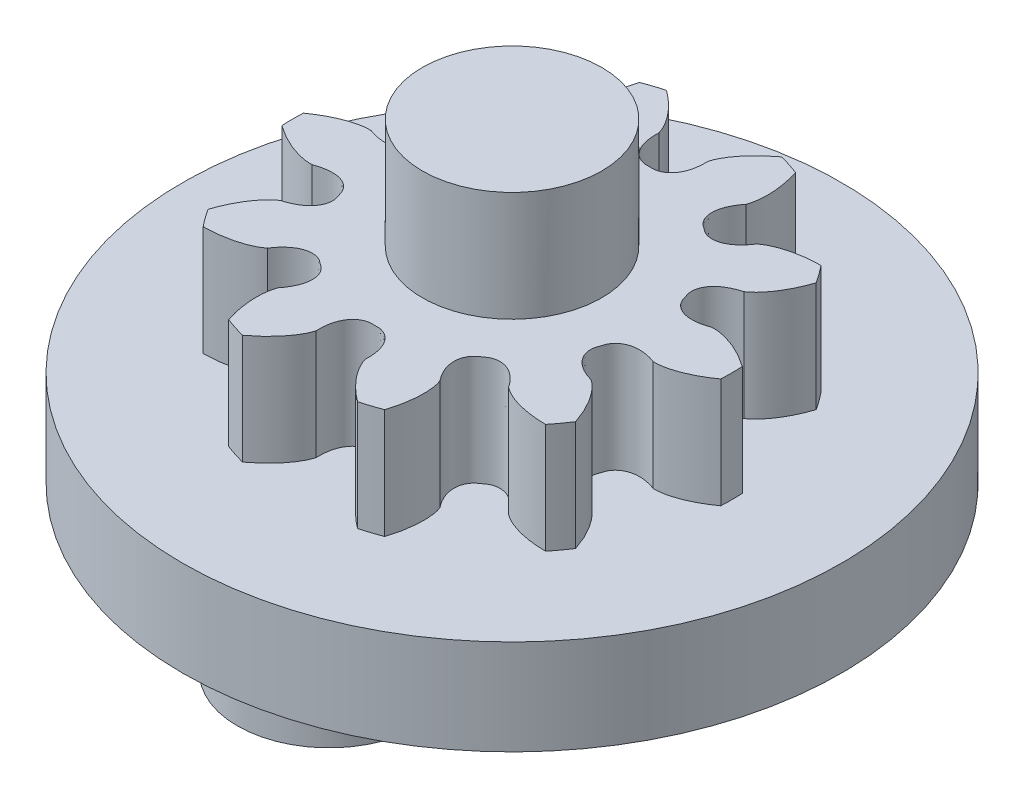
from build123d import *

# Parameters (mm, degrees)
SKETCH1_R           = 9
BOSS_EXTRUDE1_DEPTH = 2.6
SKETCH2_R           = 2.5
BOSS_EXTRUDE2_DEPTH = 7
BOSS_EXTRUDE3_DEPTH = 3
SKETCH4_R           = 2.45
BOSS_EXTRUDE4_DEPTH = 3


with BuildPart() as part:
    # Sketch1 → Boss-Extrude1 (new body)
    with BuildSketch(Plane(origin=(0, 0, 0), x_dir=(1, 0, 0), z_dir=(0, 1, 0))):
        Circle(SKETCH1_R)
    extrude(amount=BOSS_EXTRUDE1_DEPTH)

    # Sketch2 → Boss-Extrude2 (add)
    with BuildSketch(Plane.XZ):
        with Locations((-5, 0)):
            Circle(SKETCH2_R)
    extrude(amount=BOSS_EXTRUDE2_DEPTH)

    # Sketch3 → Boss-Extrude3 (add)
    with BuildSketch(Plane(origin=(0, 2.6, 0), x_dir=(1, 0, 0), z_dir=(0, 1, 0))):
        with BuildLine():
            ThreePointArc((-2.131306836, -5.60870138), (-1.854101966, -5.706339098), (-1.572448505, -5.790285459))
            add(Edge.make_bspline(
                [(-1.572448505, -5.790285459), (-1.524121757, -5.753776421), (-1.427468014, -5.680758158), (-1.29005992, -5.561733251), (-1.159069112, -5.435753819), (-1.036126032, -5.301847985), (-0.92251263, -5.159932716), (-0.837301737, -5.034588255), (-0.776335293, -4.929887877), (-0.735125884, -4.848929659), (-0.698268351, -4.765746753), (-0.680638314, -4.707778502), (-0.671824783, -4.678799267)],
                knots=[0, 0, 0, 0, 0.010251706, 0.020503464, 0.030755047, 0.041006321, 0.051257106, 0.061507029, 0.066633012, 0.071758798, 0.07688417, 0.082007812, 0.082007812, 0.082007812, 0.082007812], degree=3, weights=[1, 1, 1, 1, 1, 1, 1, 1, 1, 1, 1, 1, 1]))
            add(Edge.make_bspline(
                [(-0.671824783, -4.678799267), (-0.672788438, -4.651496326), (-0.674715723, -4.596891171), (-0.67266211, -4.514929148), (-0.666126837, -4.433177326), (-0.653115793, -4.352246289), (-0.637164096, -4.271797271), (-0.612712294, -4.193474838), (-0.58299038, -4.117042318), (-0.545673731, -4.043909177), (-0.500291897, -3.975487721), (-0.447276365, -3.912783717), (-0.386261642, -3.857704877), (-0.317525574, -3.812703152), (-0.243061735, -3.777838125), (-0.176887172, -3.760110426), (-0.122948454, -3.751154668), (-0.068263798, -3.749181842), (0, -3.750545471), (0.068263798, -3.749181842), (0.122948454, -3.751154668), (0.176887172, -3.760110426), (0.243061735, -3.777838125), (0.317525574, -3.812703152), (0.386261642, -3.857704877), (0.447276365, -3.912783717), (0.500291897, -3.975487721), (0.545673731, -4.043909177), (0.58299038, -4.117042318), (0.612712294, -4.193474838), (0.637164096, -4.271797271), (0.653115793, -4.352246289), (0.666126837, -4.433177326), (0.67266211, -4.514929148), (0.674715723, -4.596891171), (0.672788438, -4.651496326), (0.671824783, -4.678799267)],
                knots=[0, 0, 0, 0, 0.003643402, 0.007286706, 0.010929975, 0.01457286, 0.01821558, 0.021858686, 0.025500936, 0.029144127, 0.032787024, 0.036428762, 0.040069815, 0.043709849, 0.04734977, 0.050988094, 0.052810356, 0.054631699, 0.058275045, 0.061918391, 0.063739733, 0.065561995, 0.069200319, 0.07284024, 0.076480275, 0.080121327, 0.083763065, 0.087405962, 0.091049153, 0.094691403, 0.098334509, 0.101977229, 0.105620114, 0.109263383, 0.112906688, 0.116550089, 0.116550089, 0.116550089, 0.116550089], degree=3, weights=[1, 1, 1, 1, 1, 1, 1, 1, 1, 1, 1, 1, 1, 1, 1, 1, 1, 1, 1, 1, 1, 1, 1, 1, 1, 1, 1, 1, 1, 1, 1, 1, 1, 1, 1, 1, 1]))
            add(Edge.make_bspline(
                [(0.671824783, -4.678799267), (0.680638314, -4.707778502), (0.698268351, -4.765746753), (0.735125884, -4.848929659), (0.776335293, -4.929887877), (0.837301737, -5.034588255), (0.92251263, -5.159932716), (1.036126032, -5.301847985), (1.159069112, -5.435753819), (1.29005992, -5.561733251), (1.427468014, -5.680758158), (1.524121757, -5.753776421), (1.572448505, -5.790285459)],
                knots=[0, 0, 0, 0, 0.002373455, 0.004747711, 0.007122158, 0.009496697, 0.014244829, 0.01899336, 0.023742117, 0.028491018, 0.03324, 0.037988957, 0.037988957, 0.037988957, 0.037988957], degree=3, weights=[1, 1, 1, 1, 1, 1, 1, 1, 1, 1, 1, 1, 1]))
            ThreePointArc((1.572448505, -5.790285459), (1.854101966, -5.706339098), (2.131306836, -5.60870138))
            add(Edge.make_bspline(
                [(2.131306836, -5.60870138), (2.148944522, -5.550759198), (2.184219984, -5.434874537), (2.225424383, -5.257814913), (2.25734932, -5.078900947), (2.278104487, -4.898304722), (2.286603958, -4.716712576), (2.281865393, -4.565221071), (2.269646944, -4.444681509), (2.25540001, -4.354962652), (2.236324695, -4.266001953), (2.216514811, -4.208741977), (2.206611541, -4.180116819)],
                knots=[0, 0, 0, 0, 0.018166013, 0.036332118, 0.054497913, 0.072663161, 0.090827541, 0.108990394, 0.11807363, 0.127156519, 0.136238672, 0.145317761, 0.145317761, 0.145317761, 0.145317761], degree=3, weights=[1, 1, 1, 1, 1, 1, 1, 1, 1, 1, 1, 1, 1]))
            add(Edge.make_bspline(
                [(2.206611541, -4.180116819), (2.189783662, -4.158594699), (2.156128351, -4.11555103), (2.10961369, -4.048035277), (2.066848322, -3.978055327), (2.029804408, -3.904933043), (1.995422855, -3.830472247), (1.969168007, -3.75273566), (1.948287632, -3.673430349), (1.935490854, -3.592330219), (1.931988406, -3.510301326), (1.938022384, -3.428410974), (1.955009802, -3.347987702), (1.984167098, -3.271178494), (2.023916461, -3.199203349), (2.067032727, -3.145964907), (2.105406004, -3.107015163), (2.148487222, -3.073276279), (2.204515316, -3.034255025), (2.258940368, -2.993027372), (2.304340782, -2.962480587), (2.353242184, -2.938021565), (2.41719861, -2.913467142), (2.49793427, -2.897904795), (2.579994267, -2.893909908), (2.661730745, -2.902606072), (2.7414777, -2.922172928), (2.818409497, -2.950852276), (2.891585883, -2.988084054), (2.960557324, -3.032449159), (3.026376018, -3.08144093), (3.086567959, -3.137149381), (3.144664185, -3.194976265), (3.198003847, -3.257273541), (3.247841323, -3.322375128), (3.278378222, -3.367684455), (3.293646874, -3.39033942)],
                knots=[0, 0, 0, 0, 0.008194405, 0.016388591, 0.024582696, 0.03277594, 0.040968812, 0.04916255, 0.057354364, 0.065548295, 0.073741565, 0.081932227, 0.090121349, 0.09830818, 0.106494756, 0.114677741, 0.118776206, 0.122872602, 0.131066881, 0.139261161, 0.143357557, 0.147456021, 0.155639006, 0.163825582, 0.172012413, 0.180201535, 0.188392198, 0.196585467, 0.204779398, 0.212971212, 0.221164951, 0.229357823, 0.237551066, 0.245745171, 0.253939358, 0.262133762, 0.262133762, 0.262133762, 0.262133762], degree=3, weights=[1, 1, 1, 1, 1, 1, 1, 1, 1, 1, 1, 1, 1, 1, 1, 1, 1, 1, 1, 1, 1, 1, 1, 1, 1, 1, 1, 1, 1, 1, 1, 1, 1, 1, 1, 1, 1]))
            add(Edge.make_bspline(
                [(3.293646874, -3.39033942), (3.317810738, -3.408603651), (3.36614662, -3.445138275), (3.444858677, -3.490770346), (3.525783835, -3.532044637), (3.636648062, -3.580913845), (3.779260749, -3.632233938), (3.954591624, -3.68026552), (4.132762539, -3.716333486), (4.312785181, -3.741258522), (4.493911749, -3.756785244), (4.615025328, -3.759046615), (4.675581963, -3.760177297)],
                knots=[0, 0, 0, 0, 0.009079089, 0.018161243, 0.027244131, 0.036327367, 0.05449022, 0.072654601, 0.090819848, 0.108985643, 0.127151749, 0.145317761, 0.145317761, 0.145317761, 0.145317761], degree=3, weights=[1, 1, 1, 1, 1, 1, 1, 1, 1, 1, 1, 1, 1]))
            ThreePointArc((4.675581963, -3.760177297), (4.854101966, -3.526711514), (5.020975406, -3.284784006))
            add(Edge.make_bspline(
                [(5.020975406, -3.284784006), (5.001187034, -3.227540624), (4.961610188, -3.113053568), (4.890872211, -2.945589986), (4.811537037, -2.782080539), (4.722176522, -2.623775544), (4.622315553, -2.471868547), (4.529437501, -2.352094604), (4.448701191, -2.261757874), (4.384439758, -2.197547932), (4.316717717, -2.136789403), (4.267034616, -2.102109067), (4.242197256, -2.084771824)],
                knots=[0, 0, 0, 0, 0.018166013, 0.036332118, 0.054497913, 0.072663161, 0.090827541, 0.108990394, 0.11807363, 0.127156519, 0.136238672, 0.145317761, 0.145317761, 0.145317761, 0.145317761], degree=3, weights=[1, 1, 1, 1, 1, 1, 1, 1, 1, 1, 1, 1, 1]))
            add(Edge.make_bspline(
                [(4.242197256, -2.084771824), (4.215932831, -2.077251242), (4.163404679, -2.062210278), (4.086088763, -2.034929518), (4.010357671, -2.003451402), (3.937408315, -1.966068098), (3.865826097, -1.926037018), (3.798893059, -1.87857901), (3.735385989, -1.826692843), (3.677363718, -1.768603217), (3.626314804, -1.704299135), (3.583062453, -1.634501765), (3.54953395, -1.559453018), (3.527975379, -1.480174835), (3.51782736, -1.39858163), (3.521416381, -1.33016772), (3.529566929, -1.27610147), (3.544589148, -1.223483634), (3.56698071, -1.158982289), (3.586778496, -1.093638174), (3.605553252, -1.042239612), (3.630738665, -0.993708325), (3.668047774, -0.936250736), (3.724216976, -0.876205302), (3.788256773, -0.824739715), (3.859494449, -0.783731563), (3.935512201, -0.752687398), (4.01460863, -0.730670102), (4.095693859, -0.717779242), (4.177570082, -0.71313097), (4.259615165, -0.714078888), (4.341056073, -0.723768037), (4.422046697, -0.736402864), (4.50181681, -0.755450152), (4.580401928, -0.778824708), (4.631738953, -0.797531586), (4.657407806, -0.806885149)],
                knots=[0, 0, 0, 0, 0.008194405, 0.016388591, 0.024582696, 0.03277594, 0.040968812, 0.04916255, 0.057354364, 0.065548295, 0.073741565, 0.081932227, 0.090121349, 0.09830818, 0.106494756, 0.114677741, 0.118776206, 0.122872602, 0.131066881, 0.139261161, 0.143357557, 0.147456021, 0.155639006, 0.163825582, 0.172012413, 0.180201535, 0.188392198, 0.196585467, 0.204779398, 0.212971212, 0.221164951, 0.229357823, 0.237551066, 0.245745171, 0.253939358, 0.262133762, 0.262133762, 0.262133762, 0.262133762], degree=3, weights=[1, 1, 1, 1, 1, 1, 1, 1, 1, 1, 1, 1, 1, 1, 1, 1, 1, 1, 1, 1, 1, 1, 1, 1, 1, 1, 1, 1, 1, 1, 1, 1, 1, 1, 1, 1, 1]))
            add(Edge.make_bspline(
                [(4.657407806, -0.806885149), (4.687692228, -0.807458059), (4.748271292, -0.808604072), (4.838772541, -0.799255407), (4.928502789, -0.785080395), (5.046918433, -0.759452057), (5.192459714, -0.717145251), (5.362537627, -0.652946714), (5.527881144, -0.577400075), (5.688173089, -0.491750199), (5.843833939, -0.397848055), (5.943146083, -0.328488767), (5.992802028, -0.293809212)],
                knots=[0, 0, 0, 0, 0.009079089, 0.018161243, 0.027244131, 0.036327367, 0.05449022, 0.072654601, 0.090819848, 0.108985643, 0.127151749, 0.145317761, 0.145317761, 0.145317761, 0.145317761], degree=3, weights=[1, 1, 1, 1, 1, 1, 1, 1, 1, 1, 1, 1, 1]))
            ThreePointArc((5.992802028, -0.293809212), (6, 0), (5.992802028, 0.293809212))
            add(Edge.make_bspline(
                [(5.992802028, 0.293809212), (5.943146083, 0.328488767), (5.843833939, 0.397848055), (5.688173089, 0.491750199), (5.527881144, 0.577400075), (5.362537627, 0.652946714), (5.192459714, 0.717145251), (5.046918433, 0.759452057), (4.928502789, 0.785080395), (4.838772541, 0.799255407), (4.748271292, 0.808604072), (4.687692228, 0.807458059), (4.657407806, 0.806885149)],
                knots=[0, 0, 0, 0, 0.018166013, 0.036332118, 0.054497913, 0.072663161, 0.090827541, 0.108990394, 0.11807363, 0.127156519, 0.136238672, 0.145317761, 0.145317761, 0.145317761, 0.145317761], degree=3, weights=[1, 1, 1, 1, 1, 1, 1, 1, 1, 1, 1, 1, 1]))
            add(Edge.make_bspline(
                [(4.657407806, 0.806885149), (4.631738953, 0.797531586), (4.580401928, 0.778824708), (4.50181681, 0.755450152), (4.422046697, 0.736402864), (4.341056073, 0.723768037), (4.259615165, 0.714078888), (4.177570082, 0.71313097), (4.095693859, 0.717779242), (4.01460863, 0.730670102), (3.935512201, 0.752687398), (3.859494449, 0.783731563), (3.788256773, 0.824739715), (3.724216976, 0.876205302), (3.668047774, 0.936250736), (3.630738665, 0.993708325), (3.605553252, 1.042239612), (3.586778496, 1.093638174), (3.56698071, 1.158982289), (3.544589148, 1.223483634), (3.529566929, 1.27610147), (3.521416381, 1.33016772), (3.51782736, 1.39858163), (3.527975379, 1.480174835), (3.54953395, 1.559453018), (3.583062453, 1.634501765), (3.626314804, 1.704299135), (3.677363718, 1.768603217), (3.735385989, 1.826692843), (3.798893059, 1.87857901), (3.865826097, 1.926037018), (3.937408315, 1.966068098), (4.010357671, 2.003451402), (4.086088763, 2.034929518), (4.163404679, 2.062210278), (4.215932831, 2.077251242), (4.242197256, 2.084771824)],
                knots=[0, 0, 0, 0, 0.008194405, 0.016388591, 0.024582696, 0.03277594, 0.040968812, 0.04916255, 0.057354364, 0.065548295, 0.073741565, 0.081932227, 0.090121349, 0.09830818, 0.106494756, 0.114677741, 0.118776206, 0.122872602, 0.131066881, 0.139261161, 0.143357557, 0.147456021, 0.155639006, 0.163825582, 0.172012413, 0.180201535, 0.188392198, 0.196585467, 0.204779398, 0.212971212, 0.221164951, 0.229357823, 0.237551066, 0.245745171, 0.253939358, 0.262133762, 0.262133762, 0.262133762, 0.262133762], degree=3, weights=[1, 1, 1, 1, 1, 1, 1, 1, 1, 1, 1, 1, 1, 1, 1, 1, 1, 1, 1, 1, 1, 1, 1, 1, 1, 1, 1, 1, 1, 1, 1, 1, 1, 1, 1, 1, 1]))
            add(Edge.make_bspline(
                [(4.242197256, 2.084771824), (4.267034616, 2.102109067), (4.316717717, 2.136789403), (4.384439758, 2.197547932), (4.448701191, 2.261757874), (4.529437501, 2.352094604), (4.622315553, 2.471868547), (4.722176522, 2.623775544), (4.811537037, 2.782080539), (4.890872211, 2.945589986), (4.961610188, 3.113053568), (5.001187034, 3.227540624), (5.020975406, 3.284784006)],
                knots=[0, 0, 0, 0, 0.009079089, 0.018161243, 0.027244131, 0.036327367, 0.05449022, 0.072654601, 0.090819848, 0.108985643, 0.127151749, 0.145317761, 0.145317761, 0.145317761, 0.145317761], degree=3, weights=[1, 1, 1, 1, 1, 1, 1, 1, 1, 1, 1, 1, 1]))
            ThreePointArc((5.020975406, 3.284784006), (4.854101966, 3.526711514), (4.675581963, 3.760177297))
            add(Edge.make_bspline(
                [(4.675581963, 3.760177297), (4.615025328, 3.759046615), (4.493911749, 3.756785244), (4.312785181, 3.741258522), (4.132762539, 3.716333486), (3.954591624, 3.68026552), (3.779260749, 3.632233938), (3.636648062, 3.580913845), (3.525783835, 3.532044637), (3.444858677, 3.490770346), (3.36614662, 3.445138275), (3.317810738, 3.408603651), (3.293646874, 3.39033942)],
                knots=[0, 0, 0, 0, 0.018166013, 0.036332118, 0.054497913, 0.072663161, 0.090827541, 0.108990394, 0.11807363, 0.127156519, 0.136238672, 0.145317761, 0.145317761, 0.145317761, 0.145317761], degree=3, weights=[1, 1, 1, 1, 1, 1, 1, 1, 1, 1, 1, 1, 1]))
            add(Edge.make_bspline(
                [(3.293646874, 3.39033942), (3.278378222, 3.367684455), (3.247841323, 3.322375128), (3.198003847, 3.257273541), (3.144664185, 3.194976265), (3.086567959, 3.137149381), (3.026376018, 3.08144093), (2.960557324, 3.032449159), (2.891585883, 2.988084054), (2.818409497, 2.950852276), (2.7414777, 2.922172928), (2.661730745, 2.902606072), (2.579994267, 2.893909908), (2.49793427, 2.897904795), (2.41719861, 2.913467142), (2.353242184, 2.938021565), (2.304340782, 2.962480587), (2.258940368, 2.993027372), (2.204515316, 3.034255025), (2.148487222, 3.073276279), (2.105406004, 3.107015163), (2.067032727, 3.145964907), (2.023916461, 3.199203349), (1.984167098, 3.271178494), (1.955009802, 3.347987702), (1.938022384, 3.428410974), (1.931988406, 3.510301326), (1.935490854, 3.592330219), (1.948287632, 3.673430349), (1.969168007, 3.75273566), (1.995422855, 3.830472247), (2.029804408, 3.904933043), (2.066848322, 3.978055327), (2.10961369, 4.048035277), (2.156128351, 4.11555103), (2.189783662, 4.158594699), (2.206611541, 4.180116819)],
                knots=[0, 0, 0, 0, 0.008194405, 0.016388591, 0.024582696, 0.03277594, 0.040968812, 0.04916255, 0.057354364, 0.065548295, 0.073741565, 0.081932227, 0.090121349, 0.09830818, 0.106494756, 0.114677741, 0.118776206, 0.122872602, 0.131066881, 0.139261161, 0.143357557, 0.147456021, 0.155639006, 0.163825582, 0.172012413, 0.180201535, 0.188392198, 0.196585467, 0.204779398, 0.212971212, 0.221164951, 0.229357823, 0.237551066, 0.245745171, 0.253939358, 0.262133762, 0.262133762, 0.262133762, 0.262133762], degree=3, weights=[1, 1, 1, 1, 1, 1, 1, 1, 1, 1, 1, 1, 1, 1, 1, 1, 1, 1, 1, 1, 1, 1, 1, 1, 1, 1, 1, 1, 1, 1, 1, 1, 1, 1, 1, 1, 1]))
            add(Edge.make_bspline(
                [(2.206611541, 4.180116819), (2.216514811, 4.208741977), (2.236324695, 4.266001953), (2.25540001, 4.354962652), (2.269646944, 4.444681509), (2.281865393, 4.565221071), (2.286603958, 4.716712576), (2.278104487, 4.898304722), (2.25734932, 5.078900947), (2.225424383, 5.257814913), (2.184219984, 5.434874537), (2.148944522, 5.550759198), (2.131306836, 5.60870138)],
                knots=[0, 0, 0, 0, 0.009079089, 0.018161243, 0.027244131, 0.036327367, 0.05449022, 0.072654601, 0.090819848, 0.108985643, 0.127151749, 0.145317761, 0.145317761, 0.145317761, 0.145317761], degree=3, weights=[1, 1, 1, 1, 1, 1, 1, 1, 1, 1, 1, 1, 1]))
            ThreePointArc((2.131306836, 5.60870138), (1.854101966, 5.706339098), (1.572448505, 5.790285459))
            add(Edge.make_bspline(
                [(1.572448505, 5.790285459), (1.524121757, 5.753776421), (1.427468014, 5.680758158), (1.29005992, 5.561733251), (1.159069112, 5.435753819), (1.036126032, 5.301847985), (0.92251263, 5.159932716), (0.837301737, 5.034588255), (0.776335293, 4.929887877), (0.735125884, 4.848929659), (0.698268351, 4.765746753), (0.680638314, 4.707778502), (0.671824783, 4.678799267)],
                knots=[0, 0, 0, 0, 0.018166013, 0.036332118, 0.054497913, 0.072663161, 0.090827541, 0.108990394, 0.11807363, 0.127156519, 0.136238672, 0.145317761, 0.145317761, 0.145317761, 0.145317761], degree=3, weights=[1, 1, 1, 1, 1, 1, 1, 1, 1, 1, 1, 1, 1]))
            add(Edge.make_bspline(
                [(0.671824783, 4.678799267), (0.672788438, 4.651496326), (0.674715723, 4.596891171), (0.67266211, 4.514929148), (0.666126837, 4.433177326), (0.653115793, 4.352246289), (0.637164096, 4.271797271), (0.612712294, 4.193474838), (0.58299038, 4.117042318), (0.545673731, 4.043909177), (0.500291897, 3.975487721), (0.447276365, 3.912783717), (0.386261642, 3.857704877), (0.317525574, 3.812703152), (0.243061735, 3.777838125), (0.176887172, 3.760110426), (0.122948454, 3.751154668), (0.068263798, 3.749181842), (0, 3.750545471), (-0.068263798, 3.749181842), (-0.122948454, 3.751154668), (-0.176887172, 3.760110426), (-0.243061735, 3.777838125), (-0.317525574, 3.812703152), (-0.386261642, 3.857704877), (-0.447276365, 3.912783717), (-0.500291897, 3.975487721), (-0.545673731, 4.043909177), (-0.58299038, 4.117042318), (-0.612712294, 4.193474838), (-0.637164096, 4.271797271), (-0.653115793, 4.352246289), (-0.666126837, 4.433177326), (-0.67266211, 4.514929148), (-0.674715723, 4.596891171), (-0.672788438, 4.651496326), (-0.671824783, 4.678799267)],
                knots=[0, 0, 0, 0, 0.008194405, 0.016388591, 0.024582696, 0.03277594, 0.040968812, 0.04916255, 0.057354364, 0.065548295, 0.073741565, 0.081932227, 0.090121349, 0.09830818, 0.106494756, 0.114677741, 0.118776206, 0.122872602, 0.131066881, 0.139261161, 0.143357557, 0.147456021, 0.155639006, 0.163825582, 0.172012413, 0.180201535, 0.188392198, 0.196585467, 0.204779398, 0.212971212, 0.221164951, 0.229357823, 0.237551066, 0.245745171, 0.253939358, 0.262133762, 0.262133762, 0.262133762, 0.262133762], degree=3, weights=[1, 1, 1, 1, 1, 1, 1, 1, 1, 1, 1, 1, 1, 1, 1, 1, 1, 1, 1, 1, 1, 1, 1, 1, 1, 1, 1, 1, 1, 1, 1, 1, 1, 1, 1, 1, 1]))
            add(Edge.make_bspline(
                [(-0.671824783, 4.678799267), (-0.680638314, 4.707778502), (-0.698268351, 4.765746753), (-0.735125884, 4.848929659), (-0.776335293, 4.929887877), (-0.837301737, 5.034588255), (-0.92251263, 5.159932716), (-1.036126032, 5.301847985), (-1.159069112, 5.435753819), (-1.29005992, 5.561733251), (-1.427468014, 5.680758158), (-1.524121757, 5.753776421), (-1.572448505, 5.790285459)],
                knots=[0, 0, 0, 0, 0.009079089, 0.018161243, 0.027244131, 0.036327367, 0.05449022, 0.072654601, 0.090819848, 0.108985643, 0.127151749, 0.145317761, 0.145317761, 0.145317761, 0.145317761], degree=3, weights=[1, 1, 1, 1, 1, 1, 1, 1, 1, 1, 1, 1, 1]))
            ThreePointArc((-1.572448505, 5.790285459), (-1.854101966, 5.706339098), (-2.131306836, 5.60870138))
            add(Edge.make_bspline(
                [(-2.131306836, 5.60870138), (-2.148944522, 5.550759198), (-2.184219984, 5.434874537), (-2.225424383, 5.257814913), (-2.25734932, 5.078900947), (-2.278104487, 4.898304722), (-2.286603958, 4.716712576), (-2.281865393, 4.565221071), (-2.269646944, 4.444681509), (-2.25540001, 4.354962652), (-2.236324695, 4.266001953), (-2.216514811, 4.208741977), (-2.206611541, 4.180116819)],
                knots=[0, 0, 0, 0, 0.018166013, 0.036332118, 0.054497913, 0.072663161, 0.090827541, 0.108990394, 0.11807363, 0.127156519, 0.136238672, 0.145317761, 0.145317761, 0.145317761, 0.145317761], degree=3, weights=[1, 1, 1, 1, 1, 1, 1, 1, 1, 1, 1, 1, 1]))
            add(Edge.make_bspline(
                [(-2.206611541, 4.180116819), (-2.189783662, 4.158594699), (-2.156128351, 4.11555103), (-2.10961369, 4.048035277), (-2.066848322, 3.978055327), (-2.029804408, 3.904933043), (-1.995422855, 3.830472247), (-1.969168007, 3.75273566), (-1.948287632, 3.673430349), (-1.935490854, 3.592330219), (-1.931988406, 3.510301326), (-1.938022384, 3.428410974), (-1.955009802, 3.347987702), (-1.984167098, 3.271178494), (-2.023916461, 3.199203349), (-2.067032727, 3.145964907), (-2.105406004, 3.107015163), (-2.148487222, 3.073276279), (-2.204515316, 3.034255025), (-2.258940368, 2.993027372), (-2.304340782, 2.962480587), (-2.353242184, 2.938021565), (-2.41719861, 2.913467142), (-2.49793427, 2.897904795), (-2.579994267, 2.893909908), (-2.661730745, 2.902606072), (-2.7414777, 2.922172928), (-2.818409497, 2.950852276), (-2.891585883, 2.988084054), (-2.960557324, 3.032449159), (-3.026376018, 3.08144093), (-3.086567959, 3.137149381), (-3.144664185, 3.194976265), (-3.198003847, 3.257273541), (-3.247841323, 3.322375128), (-3.278378222, 3.367684455), (-3.293646874, 3.39033942)],
                knots=[0, 0, 0, 0, 0.008194405, 0.016388591, 0.024582696, 0.03277594, 0.040968812, 0.04916255, 0.057354364, 0.065548295, 0.073741565, 0.081932227, 0.090121349, 0.09830818, 0.106494756, 0.114677741, 0.118776206, 0.122872602, 0.131066881, 0.139261161, 0.143357557, 0.147456021, 0.155639006, 0.163825582, 0.172012413, 0.180201535, 0.188392198, 0.196585467, 0.204779398, 0.212971212, 0.221164951, 0.229357823, 0.237551066, 0.245745171, 0.253939358, 0.262133762, 0.262133762, 0.262133762, 0.262133762], degree=3, weights=[1, 1, 1, 1, 1, 1, 1, 1, 1, 1, 1, 1, 1, 1, 1, 1, 1, 1, 1, 1, 1, 1, 1, 1, 1, 1, 1, 1, 1, 1, 1, 1, 1, 1, 1, 1, 1]))
            add(Edge.make_bspline(
                [(-3.293646874, 3.39033942), (-3.317810738, 3.408603651), (-3.36614662, 3.445138275), (-3.444858677, 3.490770346), (-3.525783835, 3.532044637), (-3.636648062, 3.580913845), (-3.779260749, 3.632233938), (-3.954591624, 3.68026552), (-4.132762539, 3.716333486), (-4.312785181, 3.741258522), (-4.493911749, 3.756785244), (-4.615025328, 3.759046615), (-4.675581963, 3.760177297)],
                knots=[0, 0, 0, 0, 0.009079089, 0.018161243, 0.027244131, 0.036327367, 0.05449022, 0.072654601, 0.090819848, 0.108985643, 0.127151749, 0.145317761, 0.145317761, 0.145317761, 0.145317761], degree=3, weights=[1, 1, 1, 1, 1, 1, 1, 1, 1, 1, 1, 1, 1]))
            ThreePointArc((-4.675581963, 3.760177297), (-4.854101966, 3.526711514), (-5.020975406, 3.284784006))
            add(Edge.make_bspline(
                [(-5.020975406, 3.284784006), (-5.001187034, 3.227540624), (-4.961610188, 3.113053568), (-4.890872211, 2.945589986), (-4.811537037, 2.782080539), (-4.722176522, 2.623775544), (-4.622315553, 2.471868547), (-4.529437501, 2.352094604), (-4.448701191, 2.261757874), (-4.384439758, 2.197547932), (-4.316717717, 2.136789403), (-4.267034616, 2.102109067), (-4.242197256, 2.084771824)],
                knots=[0, 0, 0, 0, 0.018166013, 0.036332118, 0.054497913, 0.072663161, 0.090827541, 0.108990394, 0.11807363, 0.127156519, 0.136238672, 0.145317761, 0.145317761, 0.145317761, 0.145317761], degree=3, weights=[1, 1, 1, 1, 1, 1, 1, 1, 1, 1, 1, 1, 1]))
            add(Edge.make_bspline(
                [(-4.242197256, 2.084771824), (-4.215932831, 2.077251242), (-4.163404679, 2.062210278), (-4.086088763, 2.034929518), (-4.010357671, 2.003451402), (-3.937408315, 1.966068098), (-3.865826097, 1.926037018), (-3.798893059, 1.87857901), (-3.735385989, 1.826692843), (-3.677363718, 1.768603217), (-3.626314804, 1.704299135), (-3.583062453, 1.634501765), (-3.54953395, 1.559453018), (-3.527975379, 1.480174835), (-3.51782736, 1.39858163), (-3.521416381, 1.33016772), (-3.529566929, 1.27610147), (-3.544589148, 1.223483634), (-3.56698071, 1.158982289), (-3.586778496, 1.093638174), (-3.605553252, 1.042239612), (-3.630738665, 0.993708325), (-3.668047774, 0.936250736), (-3.724216976, 0.876205302), (-3.788256773, 0.824739715), (-3.859494449, 0.783731563), (-3.935512201, 0.752687398), (-4.01460863, 0.730670102), (-4.095693859, 0.717779242), (-4.177570082, 0.71313097), (-4.259615165, 0.714078888), (-4.341056073, 0.723768037), (-4.422046697, 0.736402864), (-4.50181681, 0.755450152), (-4.580401928, 0.778824708), (-4.631738953, 0.797531586), (-4.657407806, 0.806885149)],
                knots=[0, 0, 0, 0, 0.008194405, 0.016388591, 0.024582696, 0.03277594, 0.040968812, 0.04916255, 0.057354364, 0.065548295, 0.073741565, 0.081932227, 0.090121349, 0.09830818, 0.106494756, 0.114677741, 0.118776206, 0.122872602, 0.131066881, 0.139261161, 0.143357557, 0.147456021, 0.155639006, 0.163825582, 0.172012413, 0.180201535, 0.188392198, 0.196585467, 0.204779398, 0.212971212, 0.221164951, 0.229357823, 0.237551066, 0.245745171, 0.253939358, 0.262133762, 0.262133762, 0.262133762, 0.262133762], degree=3, weights=[1, 1, 1, 1, 1, 1, 1, 1, 1, 1, 1, 1, 1, 1, 1, 1, 1, 1, 1, 1, 1, 1, 1, 1, 1, 1, 1, 1, 1, 1, 1, 1, 1, 1, 1, 1, 1]))
            add(Edge.make_bspline(
                [(-4.657407806, 0.806885149), (-4.687692228, 0.807458059), (-4.748271292, 0.808604072), (-4.838772541, 0.799255407), (-4.928502789, 0.785080395), (-5.046918433, 0.759452057), (-5.192459714, 0.717145251), (-5.362537627, 0.652946714), (-5.527881144, 0.577400075), (-5.688173089, 0.491750199), (-5.843833939, 0.397848055), (-5.943146083, 0.328488767), (-5.992802028, 0.293809212)],
                knots=[0, 0, 0, 0, 0.009079089, 0.018161243, 0.027244131, 0.036327367, 0.05449022, 0.072654601, 0.090819848, 0.108985643, 0.127151749, 0.145317761, 0.145317761, 0.145317761, 0.145317761], degree=3, weights=[1, 1, 1, 1, 1, 1, 1, 1, 1, 1, 1, 1, 1]))
            ThreePointArc((-5.992802028, 0.293809212), (-6, 0), (-5.992802028, -0.293809212))
            add(Edge.make_bspline(
                [(-5.992802028, -0.293809212), (-5.943146083, -0.328488767), (-5.843833939, -0.397848055), (-5.688173089, -0.491750199), (-5.527881144, -0.577400075), (-5.362537627, -0.652946714), (-5.192459714, -0.717145251), (-5.046918433, -0.759452057), (-4.928502789, -0.785080395), (-4.838772541, -0.799255407), (-4.748271292, -0.808604072), (-4.687692228, -0.807458059), (-4.657407806, -0.806885149)],
                knots=[0, 0, 0, 0, 0.018166013, 0.036332118, 0.054497913, 0.072663161, 0.090827541, 0.108990394, 0.11807363, 0.127156519, 0.136238672, 0.145317761, 0.145317761, 0.145317761, 0.145317761], degree=3, weights=[1, 1, 1, 1, 1, 1, 1, 1, 1, 1, 1, 1, 1]))
            add(Edge.make_bspline(
                [(-4.657407806, -0.806885149), (-4.631738953, -0.797531586), (-4.580401928, -0.778824708), (-4.50181681, -0.755450152), (-4.422046697, -0.736402864), (-4.341056073, -0.723768037), (-4.259615165, -0.714078888), (-4.177570082, -0.71313097), (-4.095693859, -0.717779242), (-4.01460863, -0.730670102), (-3.935512201, -0.752687398), (-3.859494449, -0.783731563), (-3.788256773, -0.824739715), (-3.724216976, -0.876205302), (-3.668047774, -0.936250736), (-3.630738665, -0.993708325), (-3.605553252, -1.042239612), (-3.586778496, -1.093638174), (-3.56698071, -1.158982289), (-3.544589148, -1.223483634), (-3.529566929, -1.27610147), (-3.521416381, -1.33016772), (-3.51782736, -1.39858163), (-3.527975379, -1.480174835), (-3.54953395, -1.559453018), (-3.583062453, -1.634501765), (-3.626314804, -1.704299135), (-3.677363718, -1.768603217), (-3.735385989, -1.826692843), (-3.798893059, -1.87857901), (-3.865826097, -1.926037018), (-3.937408315, -1.966068098), (-4.010357671, -2.003451402), (-4.086088763, -2.034929518), (-4.163404679, -2.062210278), (-4.215932831, -2.077251242), (-4.242197256, -2.084771824)],
                knots=[0, 0, 0, 0, 0.008194405, 0.016388591, 0.024582696, 0.03277594, 0.040968812, 0.04916255, 0.057354364, 0.065548295, 0.073741565, 0.081932227, 0.090121349, 0.09830818, 0.106494756, 0.114677741, 0.118776206, 0.122872602, 0.131066881, 0.139261161, 0.143357557, 0.147456021, 0.155639006, 0.163825582, 0.172012413, 0.180201535, 0.188392198, 0.196585467, 0.204779398, 0.212971212, 0.221164951, 0.229357823, 0.237551066, 0.245745171, 0.253939358, 0.262133762, 0.262133762, 0.262133762, 0.262133762], degree=3, weights=[1, 1, 1, 1, 1, 1, 1, 1, 1, 1, 1, 1, 1, 1, 1, 1, 1, 1, 1, 1, 1, 1, 1, 1, 1, 1, 1, 1, 1, 1, 1, 1, 1, 1, 1, 1, 1]))
            add(Edge.make_bspline(
                [(-4.242197256, -2.084771824), (-4.267034616, -2.102109067), (-4.316717717, -2.136789403), (-4.384439758, -2.197547932), (-4.448701191, -2.261757874), (-4.529437501, -2.352094604), (-4.622315553, -2.471868547), (-4.722176522, -2.623775544), (-4.811537037, -2.782080539), (-4.890872211, -2.945589986), (-4.961610188, -3.113053568), (-5.001187034, -3.227540624), (-5.020975406, -3.284784006)],
                knots=[0, 0, 0, 0, 0.009079089, 0.018161243, 0.027244131, 0.036327367, 0.05449022, 0.072654601, 0.090819848, 0.108985643, 0.127151749, 0.145317761, 0.145317761, 0.145317761, 0.145317761], degree=3, weights=[1, 1, 1, 1, 1, 1, 1, 1, 1, 1, 1, 1, 1]))
            ThreePointArc((-5.020975406, -3.284784006), (-4.854101966, -3.526711514), (-4.675581963, -3.760177297))
            add(Edge.make_bspline(
                [(-4.675581963, -3.760177297), (-4.615025328, -3.759046615), (-4.493911749, -3.756785244), (-4.312785181, -3.741258522), (-4.132762539, -3.716333486), (-3.954591624, -3.68026552), (-3.779260749, -3.632233938), (-3.636648062, -3.580913845), (-3.525783835, -3.532044637), (-3.444858677, -3.490770346), (-3.36614662, -3.445138275), (-3.317810738, -3.408603651), (-3.293646874, -3.39033942)],
                knots=[0, 0, 0, 0, 0.018166013, 0.036332118, 0.054497913, 0.072663161, 0.090827541, 0.108990394, 0.11807363, 0.127156519, 0.136238672, 0.145317761, 0.145317761, 0.145317761, 0.145317761], degree=3, weights=[1, 1, 1, 1, 1, 1, 1, 1, 1, 1, 1, 1, 1]))
            add(Edge.make_bspline(
                [(-3.293646874, -3.39033942), (-3.278378222, -3.367684455), (-3.247841323, -3.322375128), (-3.198003847, -3.257273541), (-3.144664185, -3.194976265), (-3.086567959, -3.137149381), (-3.026376018, -3.08144093), (-2.960557324, -3.032449159), (-2.891585883, -2.988084054), (-2.818409497, -2.950852276), (-2.7414777, -2.922172928), (-2.661730745, -2.902606072), (-2.579994267, -2.893909908), (-2.49793427, -2.897904795), (-2.41719861, -2.913467142), (-2.353242184, -2.938021565), (-2.304340782, -2.962480587), (-2.258940368, -2.993027372), (-2.204515316, -3.034255025), (-2.148487222, -3.073276279), (-2.105406004, -3.107015163), (-2.067032727, -3.145964907), (-2.023916461, -3.199203349), (-1.984167098, -3.271178494), (-1.955009802, -3.347987702), (-1.938022384, -3.428410974), (-1.931988406, -3.510301326), (-1.935490854, -3.592330219), (-1.948287632, -3.673430349), (-1.969168007, -3.75273566), (-1.995422855, -3.830472247), (-2.029804408, -3.904933043), (-2.066848322, -3.978055327), (-2.10961369, -4.048035277), (-2.156128351, -4.11555103), (-2.189783662, -4.158594699), (-2.206611541, -4.180116819)],
                knots=[0, 0, 0, 0, 0.008194405, 0.016388591, 0.024582696, 0.03277594, 0.040968812, 0.04916255, 0.057354364, 0.065548295, 0.073741565, 0.081932227, 0.090121349, 0.09830818, 0.106494756, 0.114677741, 0.118776206, 0.122872602, 0.131066881, 0.139261161, 0.143357557, 0.147456021, 0.155639006, 0.163825582, 0.172012413, 0.180201535, 0.188392198, 0.196585467, 0.204779398, 0.212971212, 0.221164951, 0.229357823, 0.237551066, 0.245745171, 0.253939358, 0.262133762, 0.262133762, 0.262133762, 0.262133762], degree=3, weights=[1, 1, 1, 1, 1, 1, 1, 1, 1, 1, 1, 1, 1, 1, 1, 1, 1, 1, 1, 1, 1, 1, 1, 1, 1, 1, 1, 1, 1, 1, 1, 1, 1, 1, 1, 1, 1]))
            add(Edge.make_bspline(
                [(-2.206611541, -4.180116819), (-2.216514811, -4.208741977), (-2.236324695, -4.266001953), (-2.25540001, -4.354962652), (-2.269646944, -4.444681509), (-2.281865393, -4.565221071), (-2.286603958, -4.716712576), (-2.278104487, -4.898304722), (-2.25734932, -5.078900947), (-2.225424383, -5.257814913), (-2.184219984, -5.434874537), (-2.148944522, -5.550759198), (-2.131306836, -5.60870138)],
                knots=[0, 0, 0, 0, 0.009079089, 0.018161243, 0.027244131, 0.036327367, 0.05449022, 0.072654601, 0.090819848, 0.108985643, 0.127151749, 0.145317761, 0.145317761, 0.145317761, 0.145317761], degree=3, weights=[1, 1, 1, 1, 1, 1, 1, 1, 1, 1, 1, 1, 1]))
        make_face()
    extrude(amount=BOSS_EXTRUDE3_DEPTH)

    # Sketch4 → Boss-Extrude4 (add)
    with BuildSketch(Plane(origin=(0, 5.6, 0), x_dir=(1, 0, 0), z_dir=(0, 1, 0))):
        Circle(SKETCH4_R)
    extrude(amount=BOSS_EXTRUDE4_DEPTH)


solid = part.part
